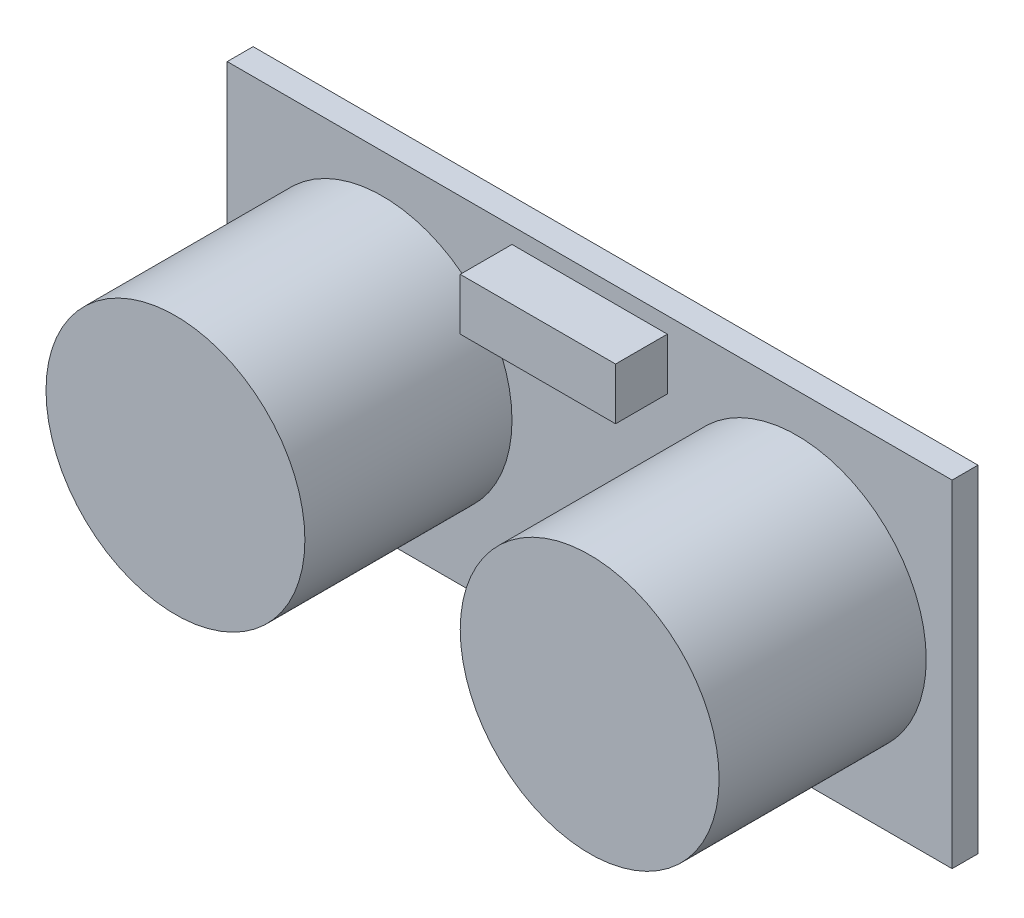
from build123d import *

# Parameters (mm, degrees)
SKETCH1_W           = 44.45
SKETCH1_H           = 20.6375
BOSS_EXTRUDE1_DEPTH = 1.5875
SKETCH2_R           = 7.9375
BOSS_EXTRUDE2_DEPTH = 12.7
SKETCH3_W           = 9.525
SKETCH3_H           = 3.175
BOSS_EXTRUDE3_DEPTH = 3.175


with BuildPart() as part:
    # Sketch1 → Boss-Extrude1 (new body)
    with BuildSketch(Plane.XY):
        Rectangle(SKETCH1_W, SKETCH1_H)
    extrude(amount=BOSS_EXTRUDE1_DEPTH)

    # Sketch2 → Boss-Extrude2 (add)
    with BuildSketch(Plane.XY.offset(1.5875)):
        with Locations((-12.7, 0)):
            Circle(SKETCH2_R)
    boss_extrude2 = extrude(amount=BOSS_EXTRUDE2_DEPTH)

    # Mirror1: Boss-Extrude2 across plane
    add(boss_extrude2.mirror(Plane(origin=(0, 0, 0), x_dir=(0, 0, 1), z_dir=(1, 0, 0))))

    # Sketch3 → Boss-Extrude3 (add)
    with BuildSketch(Plane.XY.offset(1.5875)):
        with Locations((0, 7.750431081)):
            Rectangle(SKETCH3_W, SKETCH3_H)
    extrude(amount=BOSS_EXTRUDE3_DEPTH)


solid = part.part
